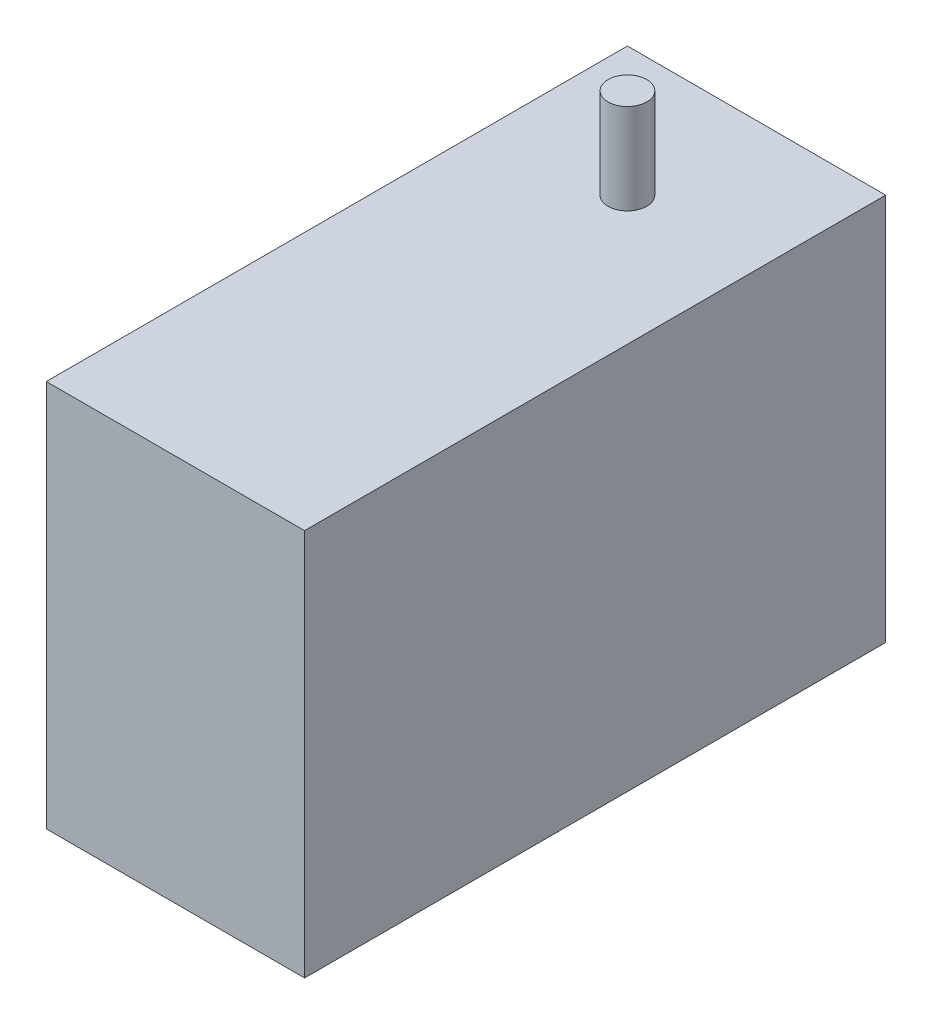
from build123d import *

# Parameters (mm, degrees)
SKETCH1_W                 = 20
SKETCH1_H                 = 45
BOSS_EXTRUDE1_DEPTH       = 30
SKETCH2_R                 = 1.5
BOSS_EXTRUDE2_DEPTH       = 7
F_4_48_TAPPED_HOLE1_D     = 2.3749
F_4_48_TAPPED_HOLE1_DEPTH = 3.5
F_4_48_TAPPED_HOLE1_TIP   = 0.713491942


with BuildPart() as part:
    # Sketch1 → Boss-Extrude1 (new body)
    with BuildSketch(Plane(origin=(0, 0, 0), x_dir=(1, 0, 0), z_dir=(0, 1, 0))):
        Rectangle(SKETCH1_W, SKETCH1_H)
    extrude(amount=BOSS_EXTRUDE1_DEPTH)

    # Sketch2 → Boss-Extrude2 (add)
    with BuildSketch(Plane(origin=(0, 30, 0), x_dir=(1, 0, 0), z_dir=(0, 1, 0))):
        with Locations((0, 12.5)):
            Circle(SKETCH2_R)
    extrude(amount=BOSS_EXTRUDE2_DEPTH)

    # #4-48 Tapped Hole1
    with Locations(Plane.ZY.offset(10)):
        with Locations((-12.8, 7.5), (-12.8, 22.5), (14.5, 22.5), (14.5, 7.5)):
            Hole(F_4_48_TAPPED_HOLE1_D / 2, depth=F_4_48_TAPPED_HOLE1_DEPTH)
            with Locations((0, 0, -(F_4_48_TAPPED_HOLE1_DEPTH + F_4_48_TAPPED_HOLE1_TIP / 2))):  # 118° drill point
                Cone(0, F_4_48_TAPPED_HOLE1_D / 2, F_4_48_TAPPED_HOLE1_TIP, mode=Mode.SUBTRACT)


solid = part.part
